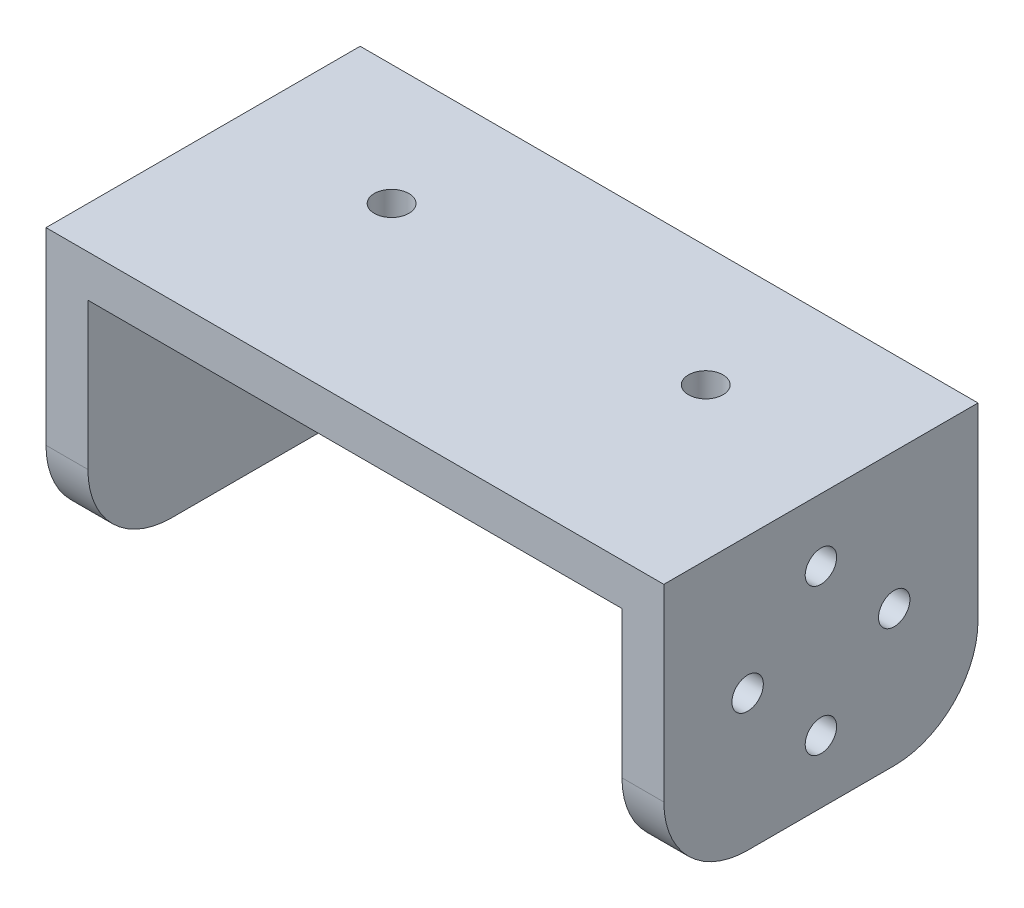
from build123d import *

# Parameters (mm, degrees)
EXTRUDE_1_DEPTH     = 30
FILLET_1_R          = 8
SKETCH_4_R          = 1.65
CUT_EXTRUDE_1_DEPTH = 10
SKETCH_5_R          = 1.65
CUT_EXTRUDE_2_DEPTH = 10
SKETCH_6_R          = 1.5
CUT_EXTRUDE_3_DEPTH = 10


with BuildPart() as part:
    # 草图1 → 凸台-拉伸1 (new body)
    with BuildSketch(Plane.XY):
        Polygon((0, 0), (29.5, 0), (29.5, -26), (25.5, -26), (25.5, -4), (0, -4), (-25.5, -4), (-25.5, -26), (-29.5, -26), (-29.5, 0), align=None)
    extrude(amount=EXTRUDE_1_DEPTH)

    # 圆角1
    fillet_1_edges = [part.edges().sort_by_distance(p)[0] for p in [
        (27.5, -26, 0),
        (-27.5, -26, 0),
        (-27.5, -26, 30),
        (27.5, -26, 30),
    ]]
    fillet(fillet_1_edges, radius=FILLET_1_R)

    # 草图4 → 切除-拉伸1 (cut)
    with BuildSketch(Plane(origin=(0, 0, 0), x_dir=(1, 0, 0), z_dir=(0, 1, 0))):
        with Locations((15, -11.5)):
            Circle(SKETCH_4_R)
        with Locations((-15, -11.5)):
            Circle(SKETCH_4_R)
    extrude(amount=-CUT_EXTRUDE_1_DEPTH, mode=Mode.SUBTRACT)

    # 草图5 → 切除-拉伸2 (cut)
    with BuildSketch(Plane.ZY.offset(29.5)):
        with Locations((15, -13)):
            Circle(SKETCH_5_R)
    extrude(amount=-CUT_EXTRUDE_2_DEPTH, mode=Mode.SUBTRACT)

    # 草图6 → 切除-拉伸3 (cut)
    with BuildSketch(Plane(origin=(29.5, 0, 0), x_dir=(0, 0, -1), z_dir=(1, 0, 0))):
        with Locations((-15, -6)):
            Circle(SKETCH_6_R)
        with Locations((-8, -13)):
            Circle(SKETCH_6_R)
        with Locations((-15, -20)):
            Circle(SKETCH_6_R)
        with Locations((-22, -13)):
            Circle(SKETCH_6_R)
    extrude(amount=-CUT_EXTRUDE_3_DEPTH, mode=Mode.SUBTRACT)


solid = part.part
